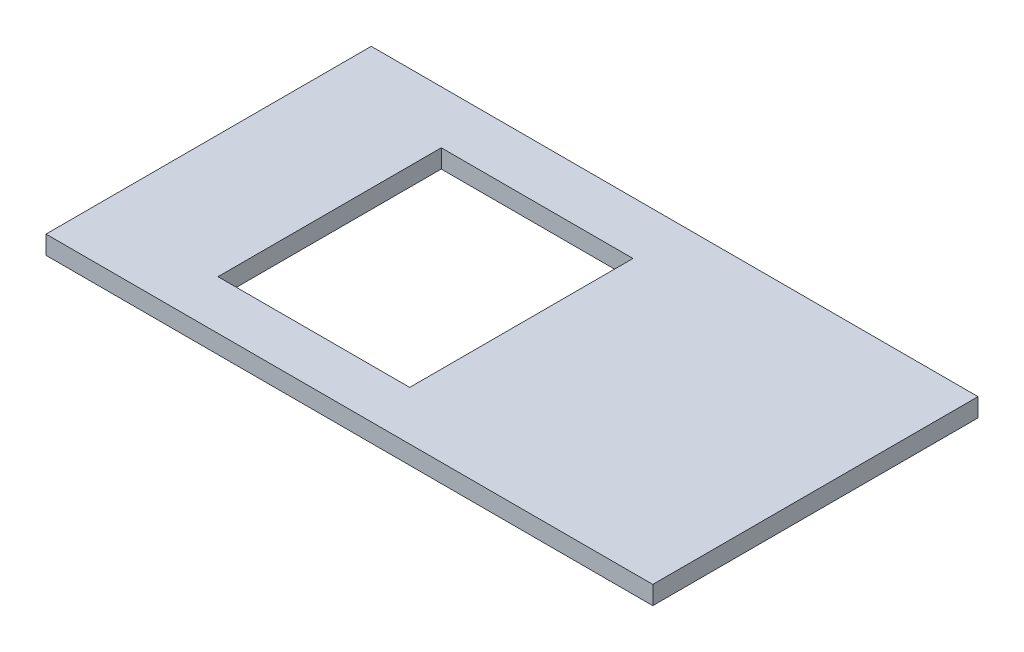
from build123d import *

# Parameters (mm, degrees)
SKETCH_1_W          = 1250
SKETCH_1_H          = 670
EXTRUDE_1_DEPTH     = 38
SKETCH_2_W          = 395
SKETCH_2_H          = 460
CUT_EXTRUDE_1_DEPTH = 39


with BuildPart() as part:
    # Эскиз1 → Бобышка-Вытянуть1 (new body)
    with BuildSketch(Plane(origin=(0, 0, 0), x_dir=(1, 0, 0), z_dir=(0, 1, 0))):
        with Locations((625, 335)):
            Rectangle(SKETCH_1_W, SKETCH_1_H)
    extrude(amount=EXTRUDE_1_DEPTH)

    # Эскиз2 → Вырез-Вытянуть1 (cut, through all)
    with BuildSketch(Plane(origin=(0, 38, 0), x_dir=(1, 0, 0), z_dir=(0, 1, 0))):
        with Locations((450.655339667, 331.116391331)):
            Rectangle(SKETCH_2_W, SKETCH_2_H)
    extrude(amount=-CUT_EXTRUDE_1_DEPTH, mode=Mode.SUBTRACT)


solid = part.part
